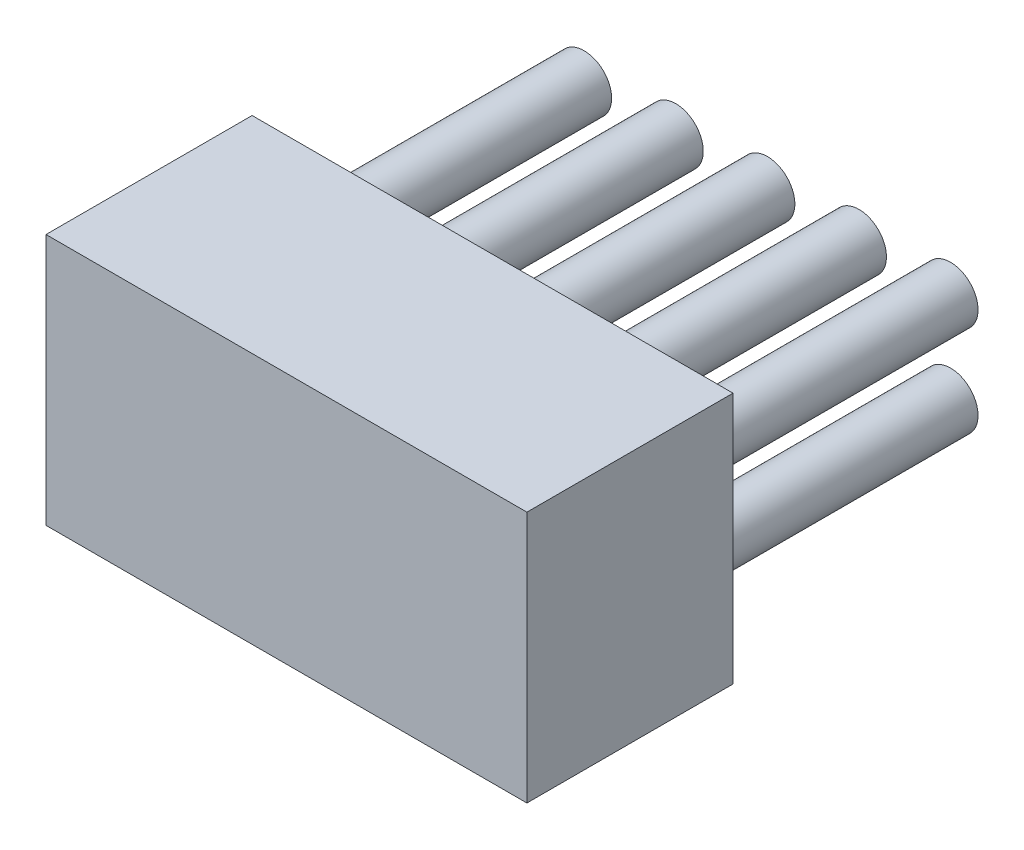
from build123d import *

# Parameters (mm, degrees)
SKETCH1_W           = 10.5
SKETCH1_H           = 5.5
BOSS_EXTRUDE1_DEPTH = 4.5
SKETCH2_R           = 0.6
BOSS_EXTRUDE2_DEPTH = 6


with BuildPart() as part:
    # Sketch1 → Boss-Extrude1 (new body)
    with BuildSketch(Plane.XY):
        with Locations((5.25, 2.75)):
            Rectangle(SKETCH1_W, SKETCH1_H)
    extrude(amount=BOSS_EXTRUDE1_DEPTH)

    # Sketch2 → Boss-Extrude2 (add)
    with BuildSketch(Plane(origin=(0, 0, 0), x_dir=(-1, 0, 0), z_dir=(0, 0, -1))):
        with Locations((-9.25, 3.75)):
            Circle(SKETCH2_R)
        with Locations((-9.25, 1.75)):
            Circle(SKETCH2_R)
        with Locations((-5.25, 1.75)):
            Circle(SKETCH2_R)
        with Locations((-7.25, 1.75)):
            Circle(SKETCH2_R)
        with Locations((-7.25, 3.75)):
            Circle(SKETCH2_R)
        with Locations((-5.25, 3.75)):
            Circle(SKETCH2_R)
        with Locations((-3.25, 3.75)):
            Circle(SKETCH2_R)
        with Locations((-1.25, 3.75)):
            Circle(SKETCH2_R)
        with Locations((-1.25, 1.75)):
            Circle(SKETCH2_R)
        with Locations((-3.25, 1.75)):
            Circle(SKETCH2_R)
    extrude(amount=BOSS_EXTRUDE2_DEPTH)


solid = part.part
